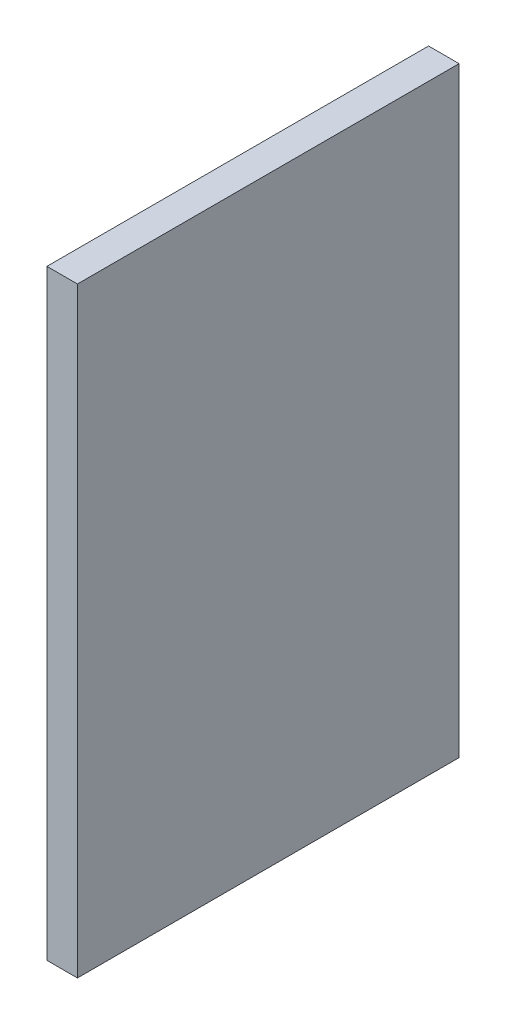
from build123d import *

# Parameters (mm, degrees)
SKETCH1_W           = 2.54
SKETCH1_H           = 31.75
BOSS_EXTRUDE1_DEPTH = 49.9999
SKETCH5_R           = 2.99974
SKETCH5_R_2         = 1.6002
BOSS_EXTRUDE3_DEPTH = 8.6106


with BuildPart() as part:
    # Sketch1 → Boss-Extrude1 (new body)
    with BuildSketch(Plane(origin=(0, 0, 0), x_dir=(1, 0, 0), z_dir=(0, 1, 0))):
        with Locations((1.27, 15.875)):
            Rectangle(SKETCH1_W, SKETCH1_H)
    extrude(amount=BOSS_EXTRUDE1_DEPTH)

    # Sketch5 → Boss-Extrude3 (add)
    with BuildSketch(Plane(origin=(0, 0, 0), x_dir=(0, 0, -1), z_dir=(1, 0, 0))):
        with Locations((15.875, 15.00124)):
            Circle(SKETCH5_R)
        with Locations((15.875, 15.00124)):
            Circle(SKETCH5_R_2, mode=Mode.SUBTRACT)
        with Locations((15.875, 35.0012)):
            Circle(SKETCH5_R)
        with Locations((15.875, 35.0012)):
            Circle(SKETCH5_R_2, mode=Mode.SUBTRACT)
    extrude(amount=-BOSS_EXTRUDE3_DEPTH)


solid = part.part
